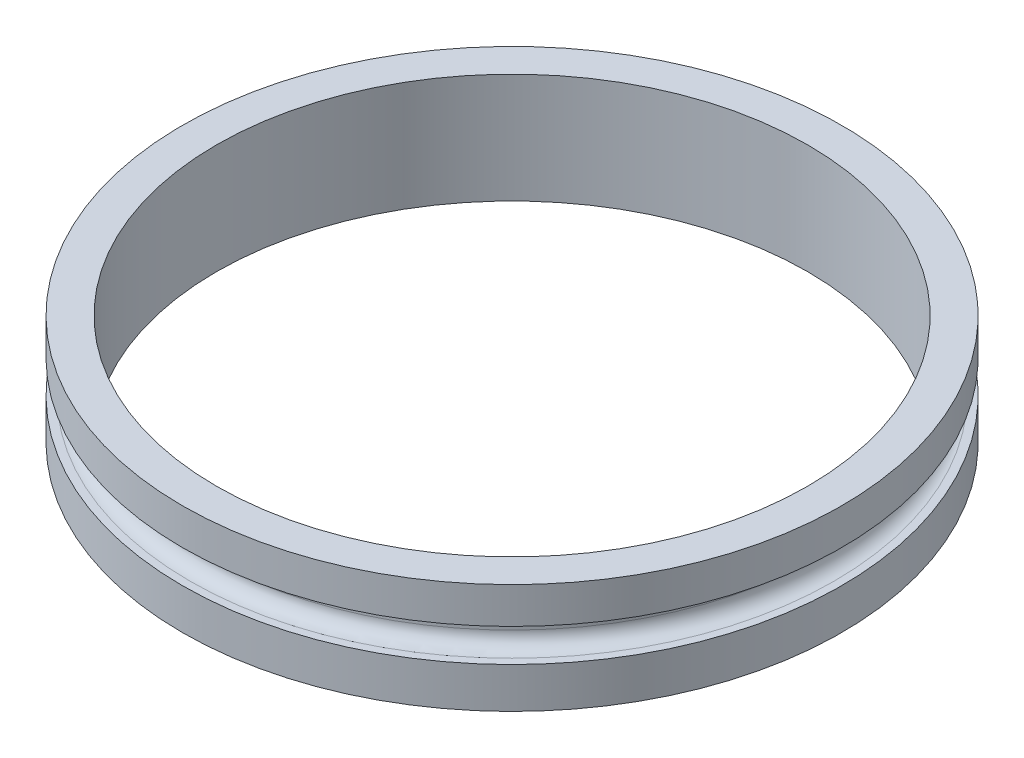
from build123d import *

# Parameters (mm, degrees)
FILLET1_R = 1.651


with BuildPart() as part:
    # Sketch1 → Revolve1 (revolve)
    with BuildSketch(Plane.XY):
        Polygon((34.1757, 0), (34.1757, 12.7), (38.1, 12.7), (38.1, 8.509), (35.56, 8.509), (35.56, 4.699), (38.1, 4.699), (38.1, 0), align=None)
    revolve(axis=Axis((0, 13.335, 0), (0, -1, 0)))

    # Fillet1
    fillet1_edges = [part.edges().sort_by_distance(p)[0] for p in [
        (-35.56, 4.699, 0),
        (-35.56, 8.509, 0),
    ]]
    fillet(fillet1_edges, radius=FILLET1_R)


solid = part.part
